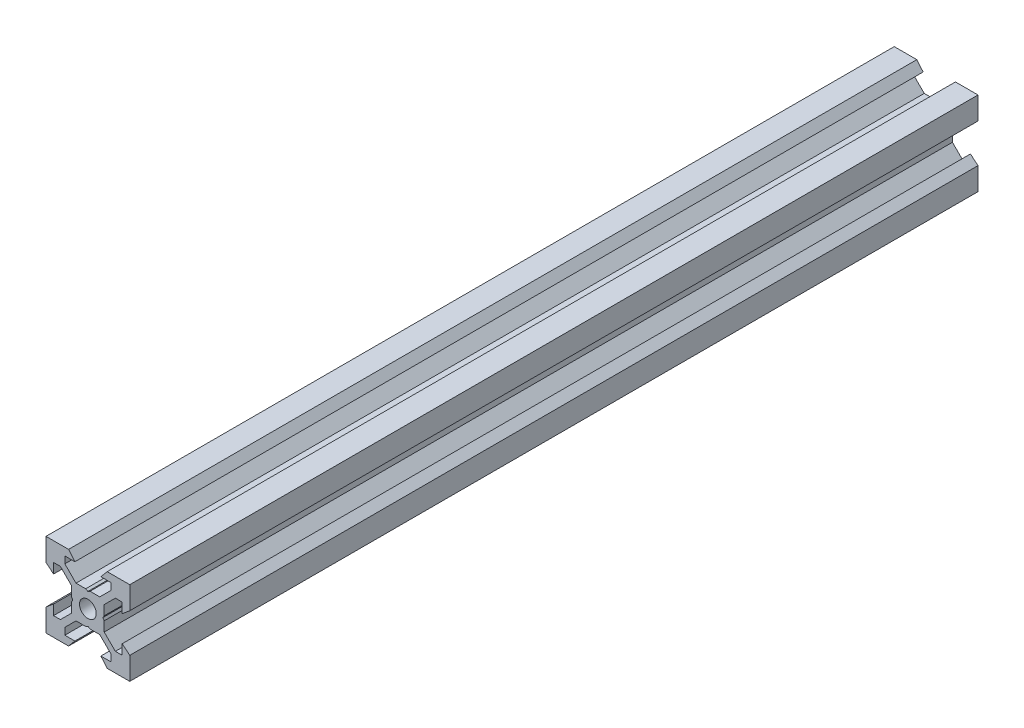
from build123d import *

# Parameters (mm, degrees)
SKETCH1_R           = 2
BOSS_EXTRUDE1_DEPTH = 101.28


with BuildPart() as part:
    # Sketch1 → Boss-Extrude1 (new body, symmetric)
    with BuildSketch(Plane.XY):
        Polygon((10, 10), (10, 4.610379336), (8.2, 3.1), (8.2, 5.5), (6.560660172, 5.5), (3.9, 2.839339828), (3.9, 0.519615242), (3.6, 0), (3.9, -0.519615242), (3.9, -2.839339828), (6.560660172, -5.5), (8.2, -5.5), (8.2, -3.1), (10, -4.610379336), (10, -10), (4.610379336, -10), (3.1, -8.2), (5.5, -8.2), (5.5, -6.560660172), (2.839339828, -3.9), (0.519615242, -3.9), (0, -3.6), (-0.519615242, -3.9), (-2.839339828, -3.9), (-5.5, -6.560660172), (-5.5, -8.2), (-3.1, -8.2), (-4.610379336, -10), (-10, -10), (-10, -4.610379336), (-8.2, -3.1), (-8.2, -5.5), (-6.560660172, -5.5), (-3.9, -2.839339828), (-3.9, -0.519615242), (-3.6, 0), (-3.9, 0.519615242), (-3.9, 2.839339828), (-6.560660172, 5.5), (-8.2, 5.5), (-8.2, 3.1), (-10, 4.610379336), (-10, 10), (-4.610379336, 10), (-3.1, 8.2), (-5.5, 8.2), (-5.5, 6.560660172), (-2.839339828, 3.9), (-0.519615242, 3.9), (0, 3.6), (0.519615242, 3.9), (2.839339828, 3.9), (5.5, 6.560660172), (5.5, 8.2), (3.1, 8.2), (4.610379336, 10), align=None)
        Circle(SKETCH1_R, mode=Mode.SUBTRACT)
    extrude(amount=BOSS_EXTRUDE1_DEPTH, both=True)


solid = part.part
